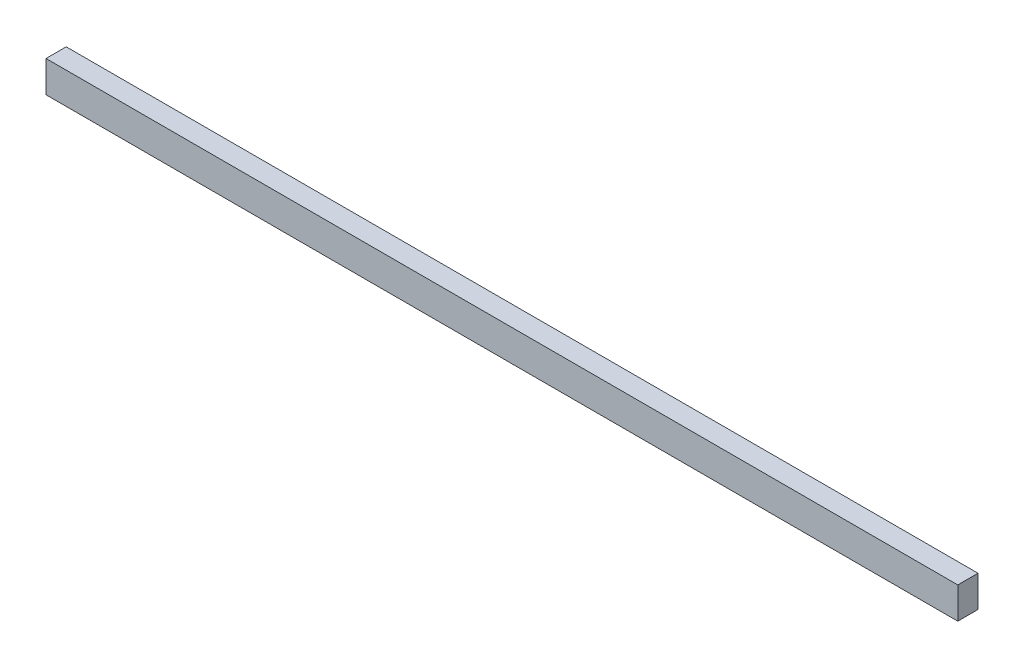
from build123d import *

# Parameters (mm, degrees)
SKETCH1_W           = 45
SKETCH1_H           = 70
BOSS_EXTRUDE1_DEPTH = 2030


with BuildPart() as part:
    # Sketch1 → Boss-Extrude1 (new body)
    with BuildSketch(Plane(origin=(0, 0, 0), x_dir=(0, 0, -1), z_dir=(1, 0, 0))):
        with Locations((22.5, 35)):
            Rectangle(SKETCH1_W, SKETCH1_H)
    extrude(amount=BOSS_EXTRUDE1_DEPTH)


solid = part.part
